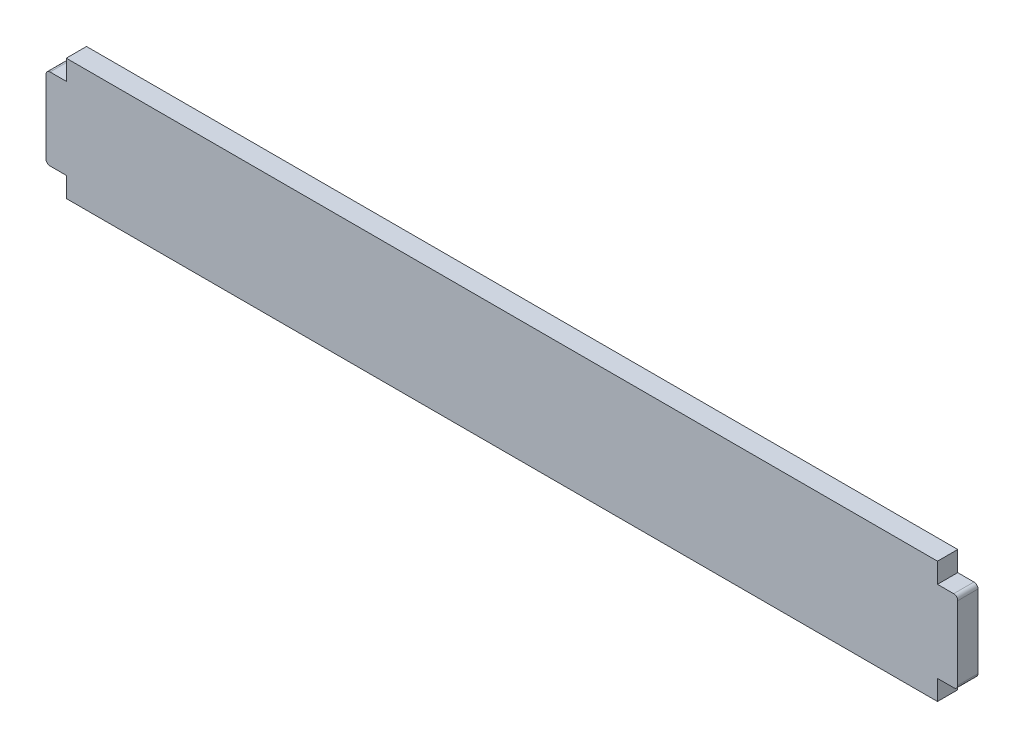
from build123d import *

# Parameters (mm, degrees)
BOSS_EXTRUDE1_DEPTH = 5
FILLET1_R           = 1


with BuildPart() as part:
    # Sketch1 → Boss-Extrude1 (new body)
    with BuildSketch(Plane.XY):
        Polygon((5, 0.05), (220, 0.05), (220, 5), (225, 5), (225, 25.1), (220, 25.1), (220, 30.05), (5, 30.05), (5, 25.1), (0, 25.1), (0, 5), (5, 5), align=None)
    extrude(amount=BOSS_EXTRUDE1_DEPTH)

    # Fillet1
    fillet1_edges = [part.edges().sort_by_distance(p)[0] for p in [
        (225, 25.1, 2.5),
        (225, 5, 2.5),
        (0, 5, 2.5),
        (0, 25.1, 2.5),
    ]]
    fillet(fillet1_edges, radius=FILLET1_R)


solid = part.part
